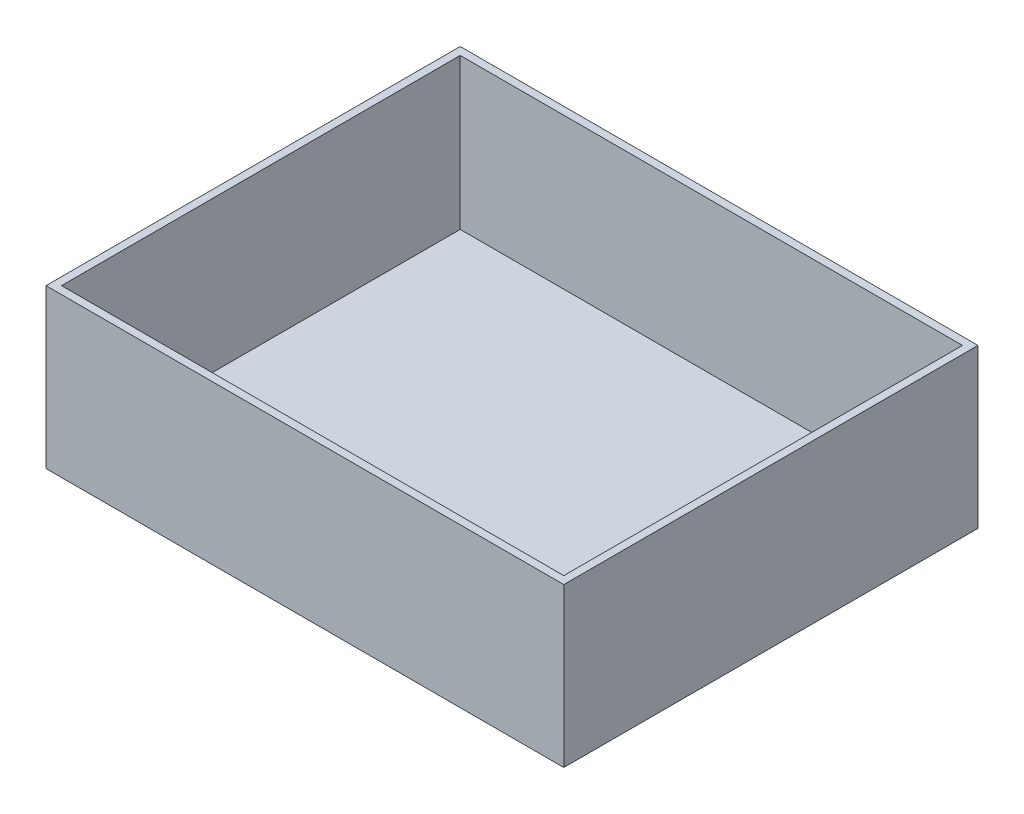
from build123d import *

# Parameters (mm, degrees)
SKETCH1_W           = 500
SKETCH1_H           = 400
BOSS_EXTRUDE1_DEPTH = 153
SHELL1_T            = -7.5


with BuildPart() as part:
    # Sketch1 → Boss-Extrude1 (new body)
    with BuildSketch(Plane(origin=(0, 0, 0), x_dir=(1, 0, 0), z_dir=(0, 1, 0))):
        Rectangle(SKETCH1_W, SKETCH1_H)
    extrude(amount=BOSS_EXTRUDE1_DEPTH)

    # Shell1
    shell1_openings = [part.faces().sort_by_distance(p)[0] for p in [
        (0, 153, 0),
    ]]
    offset(amount=SHELL1_T, openings=shell1_openings, kind=Kind.INTERSECTION)


solid = part.part
